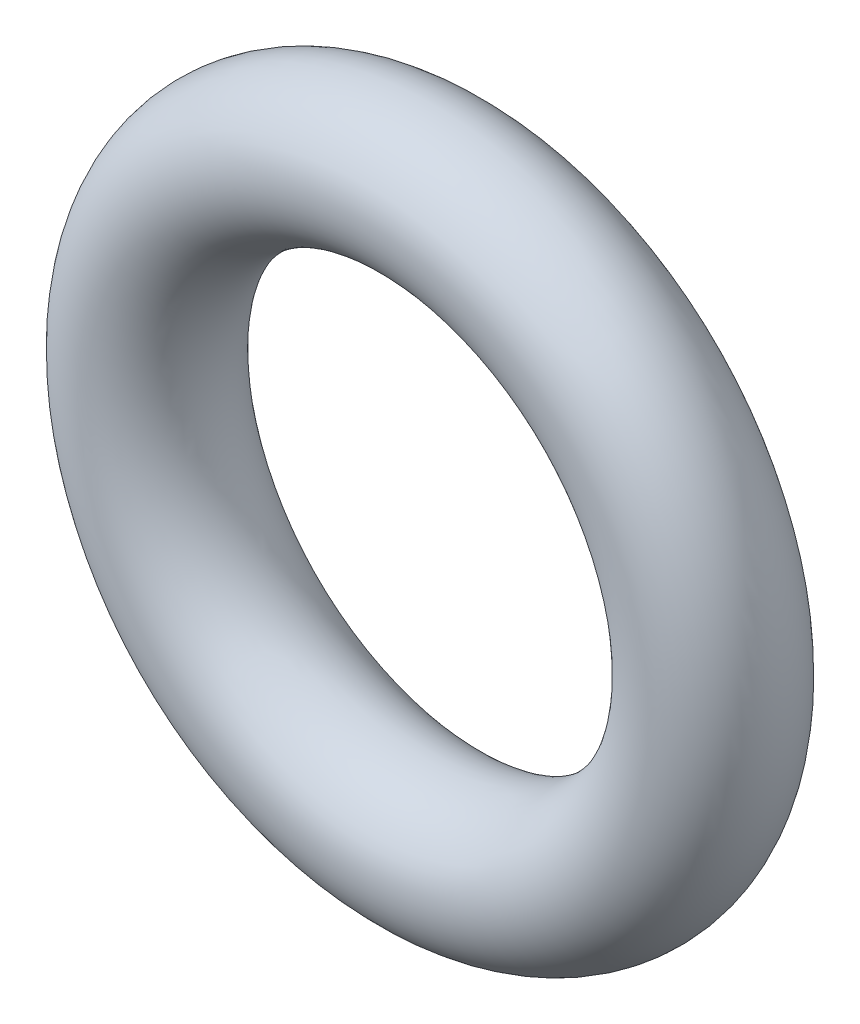
from build123d import *

# Parameters (mm, degrees)
SKETCH1_R = 0.889


with BuildPart() as part:
    # Sketch1 → Revolve1 (revolve)
    with BuildSketch(Plane(origin=(0, 0, 0), x_dir=(0, -1, 0), z_dir=(1, 0, 0))):
        with Locations((3.5306, 0)):
            Circle(SKETCH1_R)
    revolve(axis=Axis((0, 0, 0.889), (0, 0, -1)))


solid = part.part
